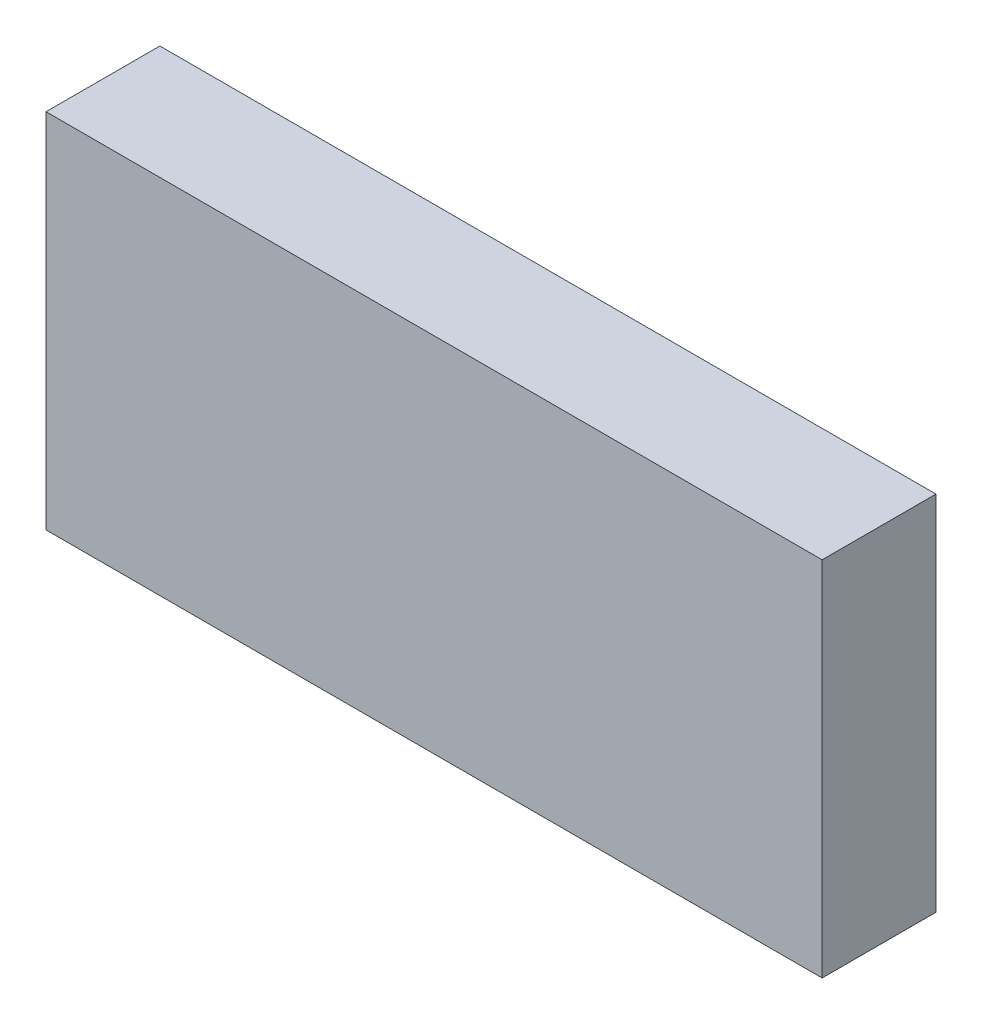
from build123d import *

# Parameters (mm, degrees)
ESQUISSE1_W        = 150
ESQUISSE1_H        = 70
BOSS_EXTRU_1_DEPTH = 22


with BuildPart() as part:
    # Esquisse1 → Boss.-Extru.1 (new body)
    with BuildSketch(Plane.XY):
        Rectangle(ESQUISSE1_W, ESQUISSE1_H)
    extrude(amount=BOSS_EXTRU_1_DEPTH)


solid = part.part
